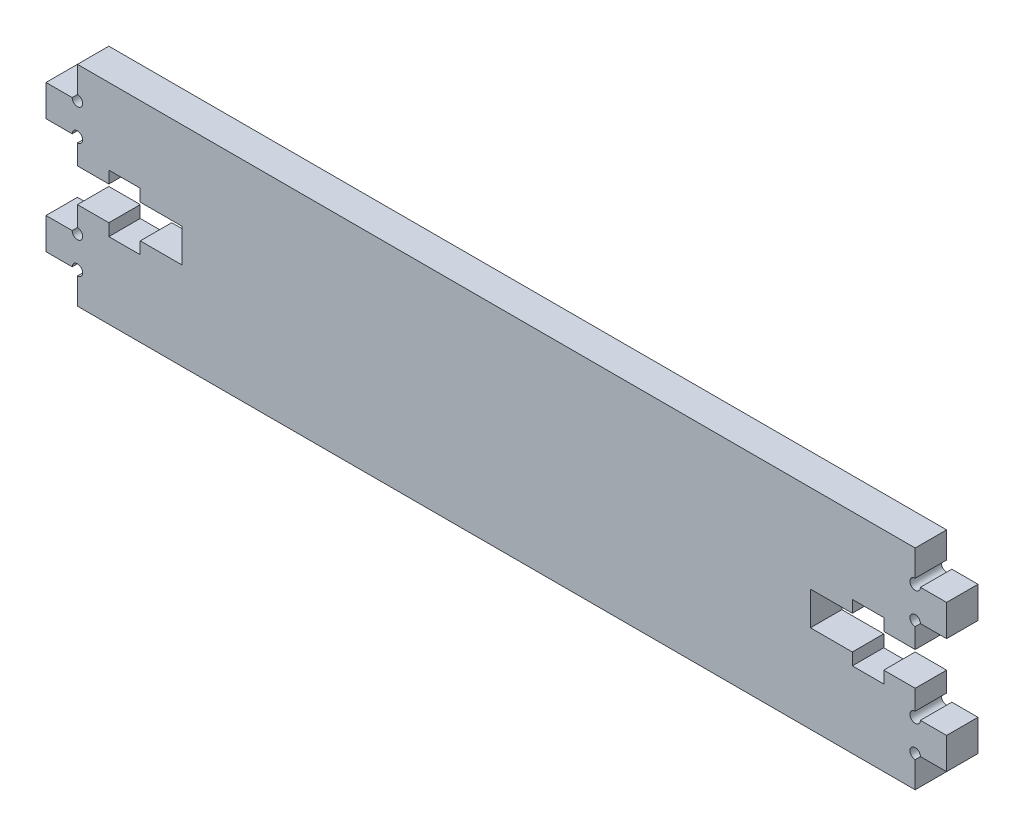
from build123d import *

# Parameters (mm, degrees)
BOSS_EXTRUDE1_DEPTH = 3
SKETCH2_R           = 0.5
CUT_EXTRUDE1_DEPTH  = 4


with BuildPart() as part:
    # Sketch1 → Boss-Extrude1 (new body)
    with BuildSketch(Plane.XY):
        Polygon((-47.039949999, -12), (-47.039949999, -15), (32.960050001, -15), (32.960050001, -12), (35.960050001, -12), (35.960050001, -9), (32.960050001, -9), (32.960050001, -6.6), (29.960050001, -6.6), (29.960050001, -7.75), (26.960050001, -7.75), (26.960050001, -6.6), (22.960050001, -6.6), (22.960050001, -3.4), (26.960050001, -3.4), (26.960050001, -2.25), (29.960050001, -2.25), (29.960050001, -3.4), (32.960050001, -3.4), (32.960050001, -1), (35.960050001, -1), (35.960050001, 2), (32.960050001, 2), (32.960050001, 5), (-47.039949999, 5), (-47.039949999, 2), (-50.039949999, 2), (-50.039949999, -1), (-47.039949999, -1), (-47.039949999, -3.4), (-44.039949999, -3.4), (-44.039949999, -2.25), (-41.039949999, -2.25), (-41.039949999, -3.4), (-37.039949999, -3.4), (-37.039949999, -6.6), (-41.039949999, -6.6), (-41.039949999, -7.75), (-44.039949999, -7.75), (-44.039949999, -6.6), (-47.039949999, -6.6), (-47.039949999, -9), (-50.039949999, -9), (-50.039949999, -12), align=None)
    extrude(amount=BOSS_EXTRUDE1_DEPTH)

    # Sketch2 → Cut-Extrude1 (cut, through all)
    with BuildSketch(Plane.XY.offset(3)):
        with Locations((-47.039949999, 2)):
            Circle(SKETCH2_R)
        with Locations((-47.039949999, -1)):
            Circle(SKETCH2_R)
        with Locations((-47.039949999, -12)):
            Circle(SKETCH2_R)
        with Locations((-47.039949999, -9)):
            Circle(SKETCH2_R)
        with Locations((32.960050001, 2)):
            Circle(SKETCH2_R)
        with Locations((32.960050001, -1)):
            Circle(SKETCH2_R)
        with Locations((32.960050001, -9)):
            Circle(SKETCH2_R)
        with Locations((32.960050001, -12)):
            Circle(SKETCH2_R)
    extrude(amount=-CUT_EXTRUDE1_DEPTH, mode=Mode.SUBTRACT)


solid = part.part
